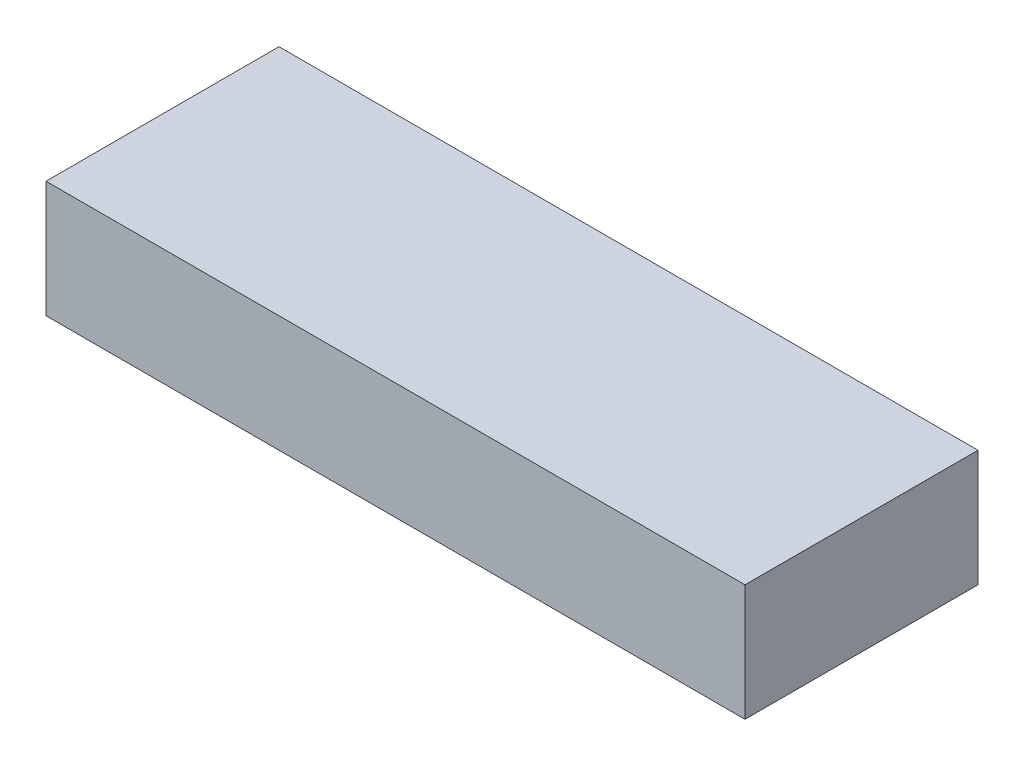
from build123d import *

# Parameters (mm, degrees)
SKETCH1_W           = 60
SKETCH1_H           = 20
BOSS_EXTRUDE1_DEPTH = 10


with BuildPart() as part:
    # Sketch1 → Boss-Extrude1 (new body)
    with BuildSketch(Plane(origin=(0, 0, 0), x_dir=(1, 0, 0), z_dir=(0, 1, 0))):
        Rectangle(SKETCH1_W, SKETCH1_H)
    extrude(amount=BOSS_EXTRUDE1_DEPTH)


solid = part.part
